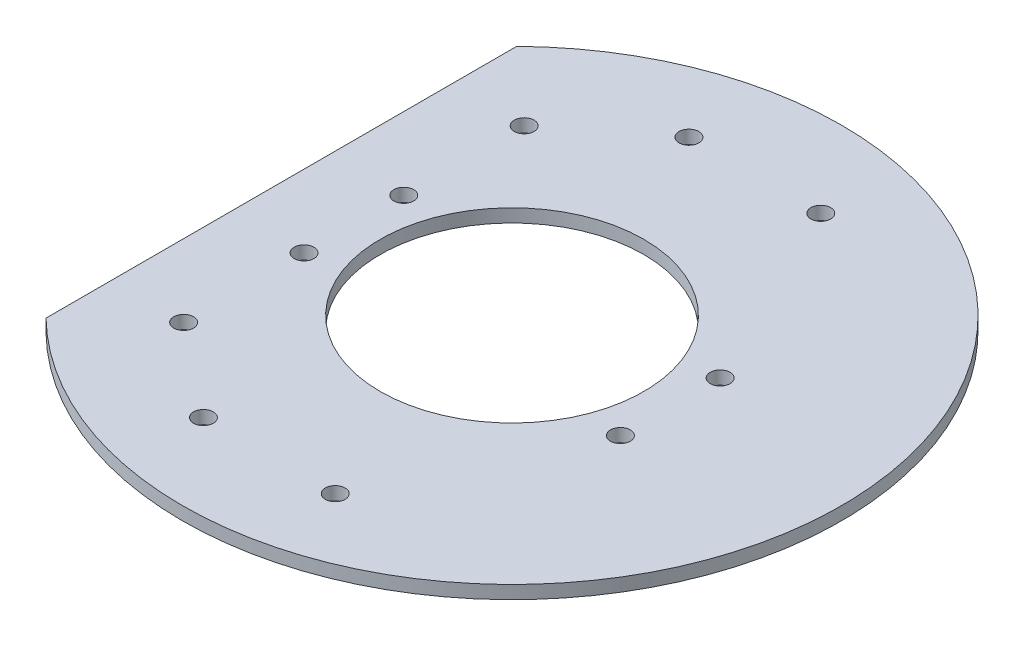
from build123d import *

# Parameters (mm, degrees)
SKETCH1_R           = 20
BOSS_EXTRUDE1_DEPTH = 2
SKETCH2_R           = 1.5
SKETCH2_R_2         = 1
CUT_EXTRUDE1_DEPTH  = 2


with BuildPart() as part:
    # Sketch1 → Boss-Extrude1 (new body)
    with BuildSketch(Plane(origin=(0, 0, 0), x_dir=(1, 0, 0), z_dir=(0, 1, 0))):
        with BuildLine():
            Line((-35, 35.707142143), (-35, -35.707142143))
            ThreePointArc((-35, -35.707142143), (50, 0), (-35, 35.707142143))
        make_face()
        Circle(SKETCH1_R, mode=Mode.SUBTRACT)
    extrude(amount=BOSS_EXTRUDE1_DEPTH)

    # Sketch2 → Cut-Extrude1 (cut)
    with BuildSketch(Plane(origin=(0, 2, 0), x_dir=(1, 0, 0), z_dir=(0, 1, 0))):
        with Locations((-23.99076058, 7.565582695)):
            Circle(SKETCH2_R)
        with Locations((24.00923942, 7.565582695)):
            Circle(SKETCH2_R)
        with Locations((-23.99076058, -25.834417305)):
            Circle(SKETCH2_R)
        with Locations((-9.99076058, -36.834417305)):
            Circle(SKETCH2_R)
        with Locations((10.00923942, -36.834417305)):
            Circle(SKETCH2_R)
        with Locations((0.00923942, 0.065582695)):
            Circle(SKETCH2_R_2)
    cut_extrude1 = extrude(amount=-CUT_EXTRUDE1_DEPTH, mode=Mode.SUBTRACT)

    # Mirror1: Cut-Extrude1 across plane
    add(cut_extrude1.mirror(Plane.XY), mode=Mode.SUBTRACT)


solid = part.part
